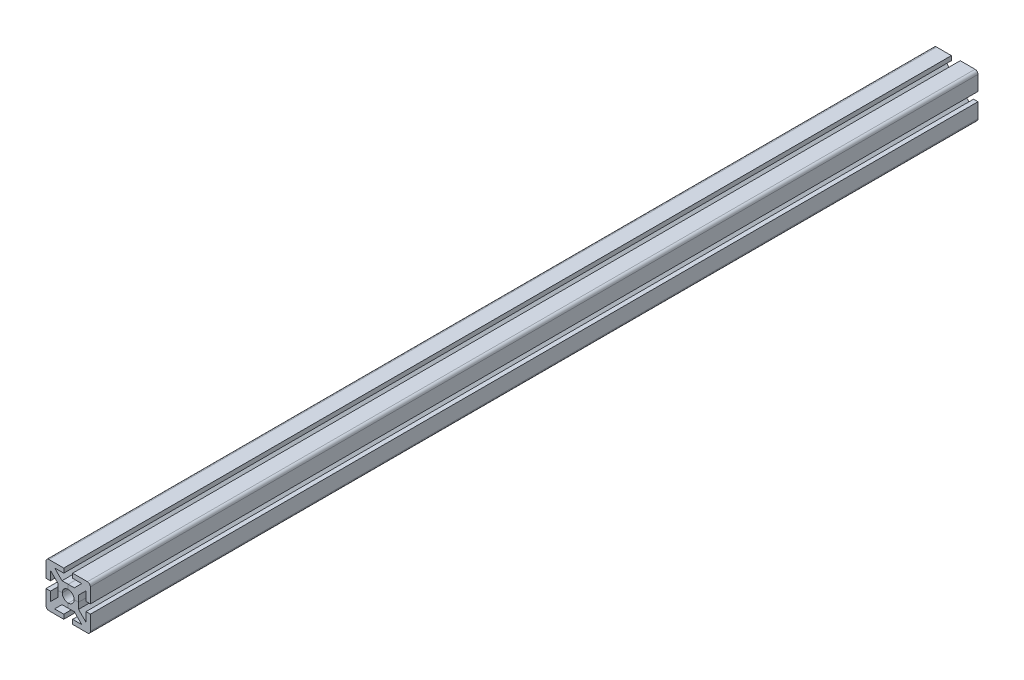
from build123d import *

# Parameters (mm, degrees)
SALIENTE_EXTRUIR1_DEPTH = 300
REDONDEO1_R             = 2
MATRIZC4_COUNT          = 4


with BuildPart() as part:
    # Croquis1 → Saliente-Extruir1 (new body, symmetric)
    with BuildSketch(Plane.XY):
        with BuildLine():
            Line((0, 4), (0, 7))
            Line((0, 7), (4.171572875, 7))
            Line((4.171572875, 7), (9.171572875, 12))
            Line((9.171572875, 12), (3, 12))
            Line((3, 12), (3, 15))
            Line((3, 15), (15, 15))
            Line((15, 15), (2.828427125, 2.828427125))
            ThreePointArc((2.828427125, 2.828427125), (1.530733729, 3.69551813), (0, 4))
        make_face()
    saliente_extruir1 = extrude(amount=SALIENTE_EXTRUIR1_DEPTH, both=True)

    # Simetría1: Saliente-Extruir1 across plane
    add(saliente_extruir1.mirror(Plane(origin=(2.828427125, 2.828427125, 300), x_dir=(0, 0, 1), z_dir=(-0.707106781, 0.707106781, 0))))

    # Redondeo1
    redondeo1_edges = [part.edges().sort_by_distance(p)[0] for p in [
        (15, 15, 0),
    ]]
    fillet(redondeo1_edges, radius=REDONDEO1_R)


with BuildPart() as matrizc4_1:
    # MatrizC4: pattern copy
    add(part.part.rotate(Axis((0, 0, 0), (0, 0, 1)), 1 * 360 / MATRIZC4_COUNT))


with BuildPart() as matrizc4_2:
    # MatrizC4: pattern copy
    add(part.part.rotate(Axis((0, 0, 0), (0, 0, 1)), 2 * 360 / MATRIZC4_COUNT))


with BuildPart() as matrizc4_3:
    # MatrizC4: pattern copy
    add(part.part.rotate(Axis((0, 0, 0), (0, 0, 1)), 3 * 360 / MATRIZC4_COUNT))


solid = Compound([part.part, matrizc4_1.part, matrizc4_2.part, matrizc4_3.part])
